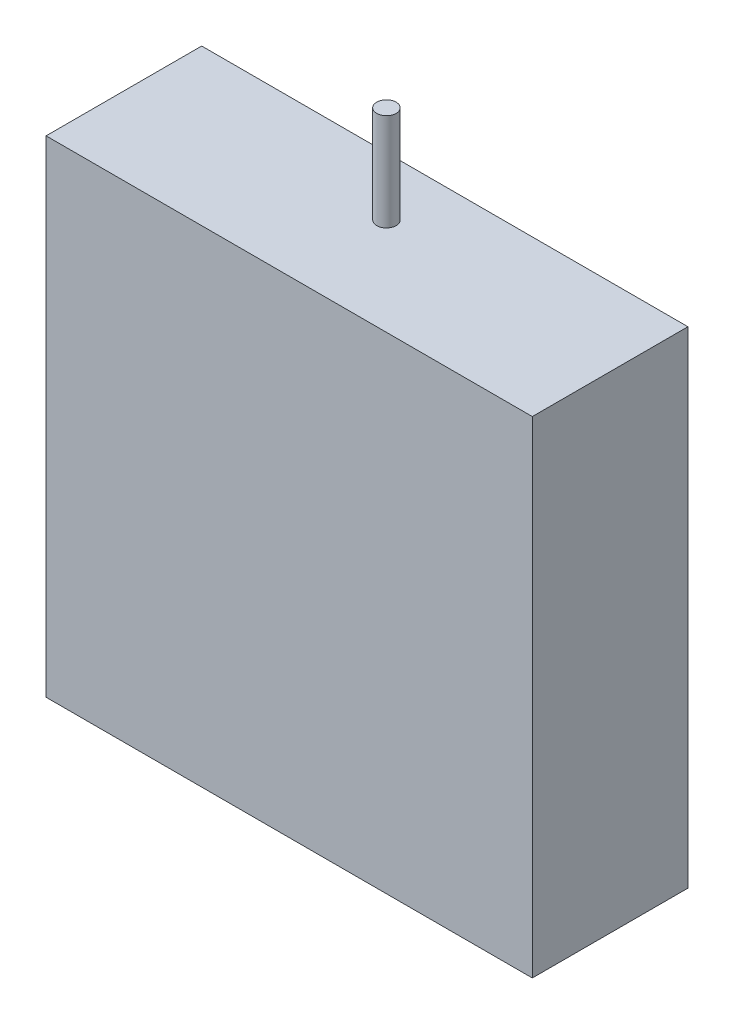
from build123d import *

# Parameters (mm, degrees)
SKETCH1_W           = 25
SKETCH1_H           = 25
BOSS_EXTRUDE1_DEPTH = 8
SKETCH2_R           = 0.5
BOSS_EXTRUDE2_DEPTH = 5


with BuildPart() as part:
    # Sketch1 → Boss-Extrude1 (new body)
    with BuildSketch(Plane.XY):
        Rectangle(SKETCH1_W, SKETCH1_H)
    extrude(amount=BOSS_EXTRUDE1_DEPTH)

    # Sketch2 → Boss-Extrude2 (add)
    with BuildSketch(Plane(origin=(0, 12.5, 0), x_dir=(1, 0, 0), z_dir=(0, 1, 0))):
        with Locations((0, -3)):
            Circle(SKETCH2_R)
    extrude(amount=BOSS_EXTRUDE2_DEPTH)


solid = part.part
